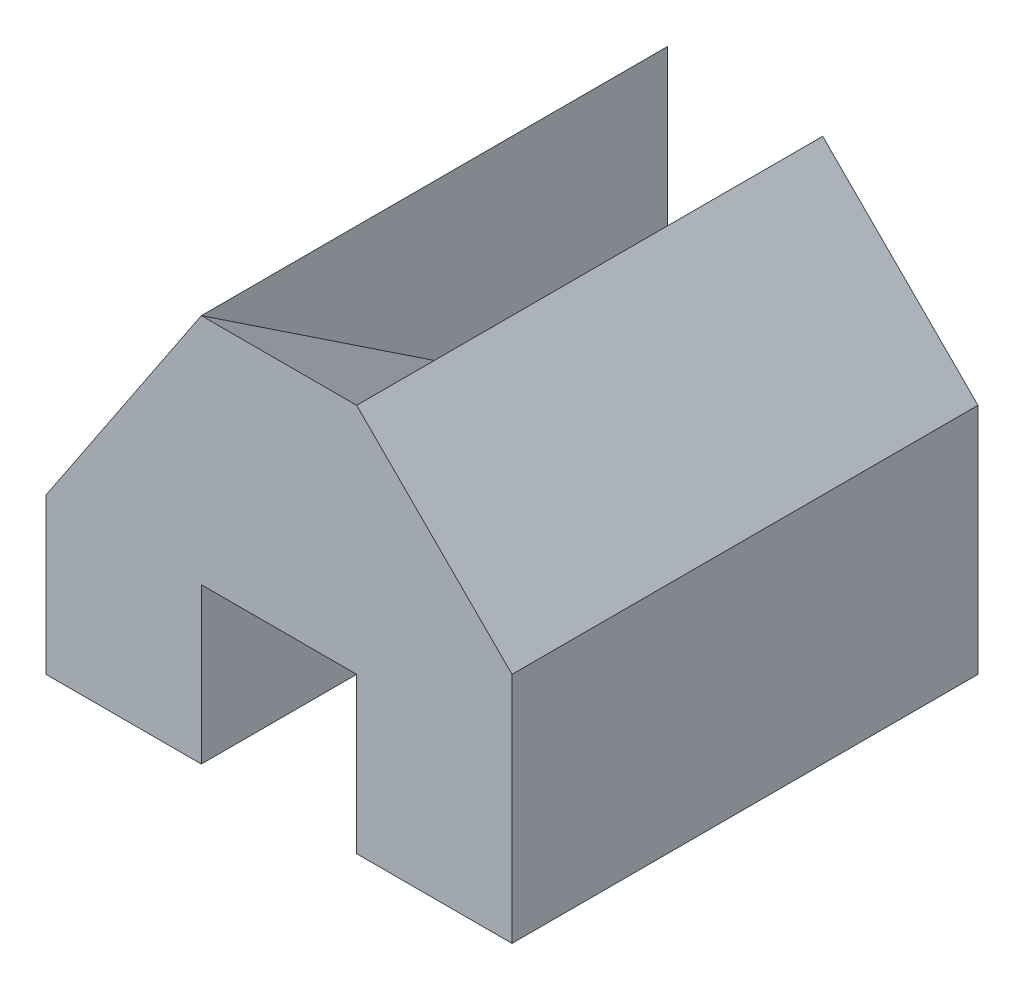
from build123d import *

# Parameters (mm, degrees)
SKETCH1_W           = 6
SKETCH1_H           = 6
BOSS_EXTRUDE1_DEPTH = 5
CUT_EXTRUDE8_DEPTH  = 1
CUT_EXTRUDE11_DEPTH = 12


with BuildPart() as part:
    # Sketch1 → Boss-Extrude1 (new body)
    with BuildSketch(Plane(origin=(0, 0, 0), x_dir=(1, 0, 0), z_dir=(0, 1, 0))):
        Rectangle(SKETCH1_W, SKETCH1_H)
    extrude(amount=BOSS_EXTRUDE1_DEPTH)

    # Sketch9 → Cut-Extrude8 (cut, symmetric)
    with BuildSketch(Plane(origin=(0, 0, 0), x_dir=(0, 0, -1), z_dir=(1, 0, 0))):
        Polygon((3, 5), (-3, 5), (3, 1), align=None)
        Polygon((3, 0), (-3, 2), (-3, 0), align=None)
    extrude(amount=CUT_EXTRUDE8_DEPTH, both=True, mode=Mode.SUBTRACT)

    # Sketch10 → Cut-Extrude11 (cut)
    with BuildSketch(Plane.XY.offset(3)):
        Polygon((-3, 2), (-1, 5), (-3, 5), align=None)
        Polygon((3, 5), (1, 5), (3, 3), align=None)
    extrude(amount=-CUT_EXTRUDE11_DEPTH, mode=Mode.SUBTRACT)


solid = part.part
